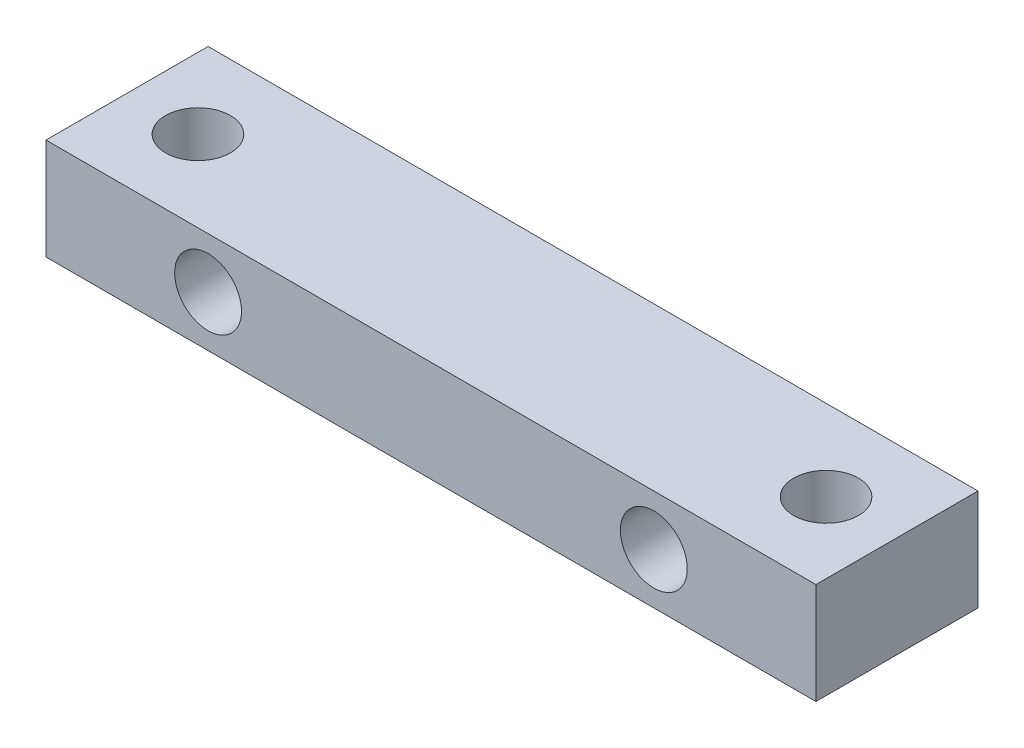
from build123d import *

# Parameters (mm, degrees)
CROQUIS1_W                          = 38
CROQUIS1_H                          = 5
SALIENTE_EXTRUIR1_DEPTH             = 8
DI_METRO_DE_TALADRO_3_2_3_2_1_D     = 3.2
DI_METRO_DE_TALADRO_3_2_3_2_1_DEPTH = 12
DI_METRO_DE_TALADRO_3_2_3_2_1_TIP   = 0.96137699
TALADRO_ROSCADO_M41_D               = 3.3
TALADRO_ROSCADO_M41_DEPTH           = 8


with BuildPart() as part:
    # Croquis1 → Saliente-Extruir1 (new body)
    with BuildSketch(Plane.XY):
        with Locations((19, 2.5)):
            Rectangle(CROQUIS1_W, CROQUIS1_H)
    extrude(amount=SALIENTE_EXTRUIR1_DEPTH)

    # Diámetro de taladro Ø3.2 (3.2)1
    with Locations(Plane(origin=(3.5, 5, 4), x_dir=(0, 0, 1), z_dir=(0, 1, 0))):
        with Locations((0, 0), (0, 31)):
            Hole(DI_METRO_DE_TALADRO_3_2_3_2_1_D / 2, depth=DI_METRO_DE_TALADRO_3_2_3_2_1_DEPTH)
            with Locations((0, 0, -(DI_METRO_DE_TALADRO_3_2_3_2_1_DEPTH + DI_METRO_DE_TALADRO_3_2_3_2_1_TIP / 2))):  # 118° drill point
                Cone(0, DI_METRO_DE_TALADRO_3_2_3_2_1_D / 2, DI_METRO_DE_TALADRO_3_2_3_2_1_TIP, mode=Mode.SUBTRACT)

    # Taladro roscado M41
    with Locations(Plane(origin=(8, 2.5, 0), x_dir=(-1, 0, 0), z_dir=(0, 0, -1))):
        with Locations((0, 0), (-22, 0)):
            Hole(TALADRO_ROSCADO_M41_D / 2, depth=TALADRO_ROSCADO_M41_DEPTH)


solid = part.part
